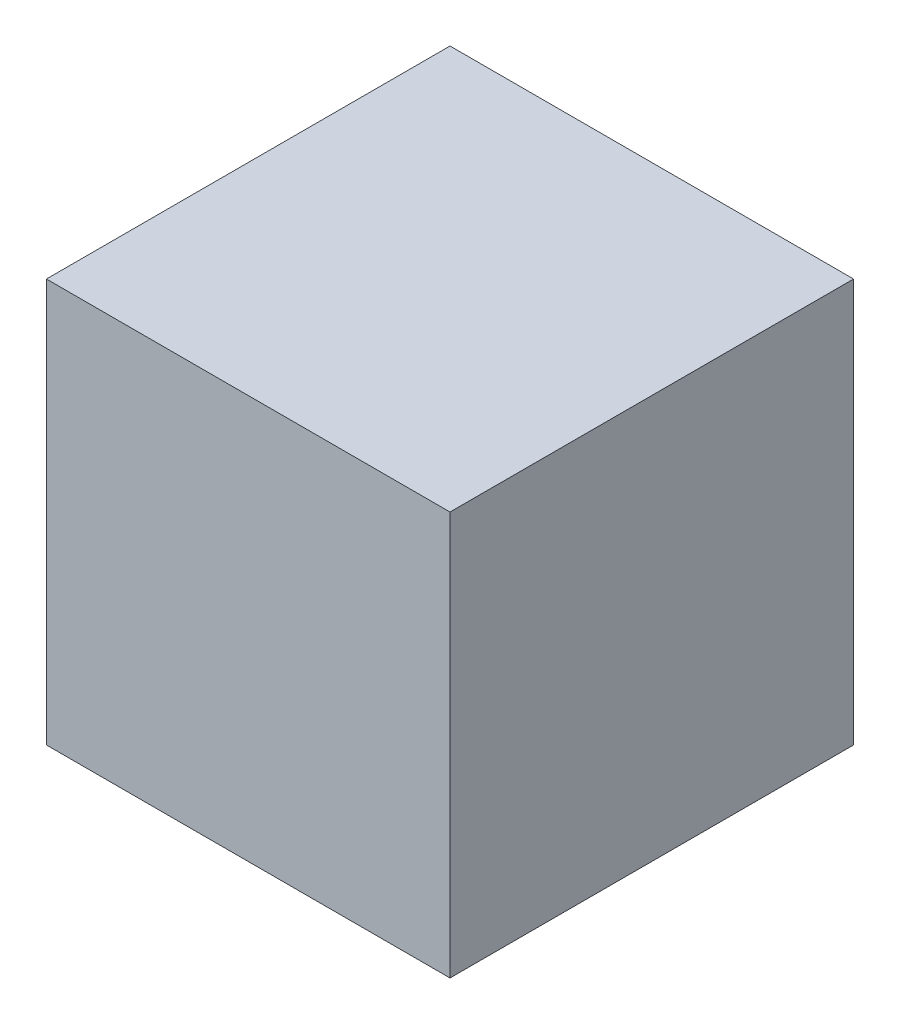
from build123d import *

# Parameters (mm, degrees)
SKETCH1_W           = 273.05
SKETCH1_H           = 273.05
BOSS_EXTRUDE1_DEPTH = 273.05


with BuildPart() as part:
    # Sketch1 → Boss-Extrude1 (new body)
    with BuildSketch(Plane(origin=(0, 0, 0), x_dir=(1, 0, 0), z_dir=(0, 1, 0))):
        with Locations((-44.252931034, 24.95112069)):
            Rectangle(SKETCH1_W, SKETCH1_H)
    extrude(amount=BOSS_EXTRUDE1_DEPTH)


solid = part.part
